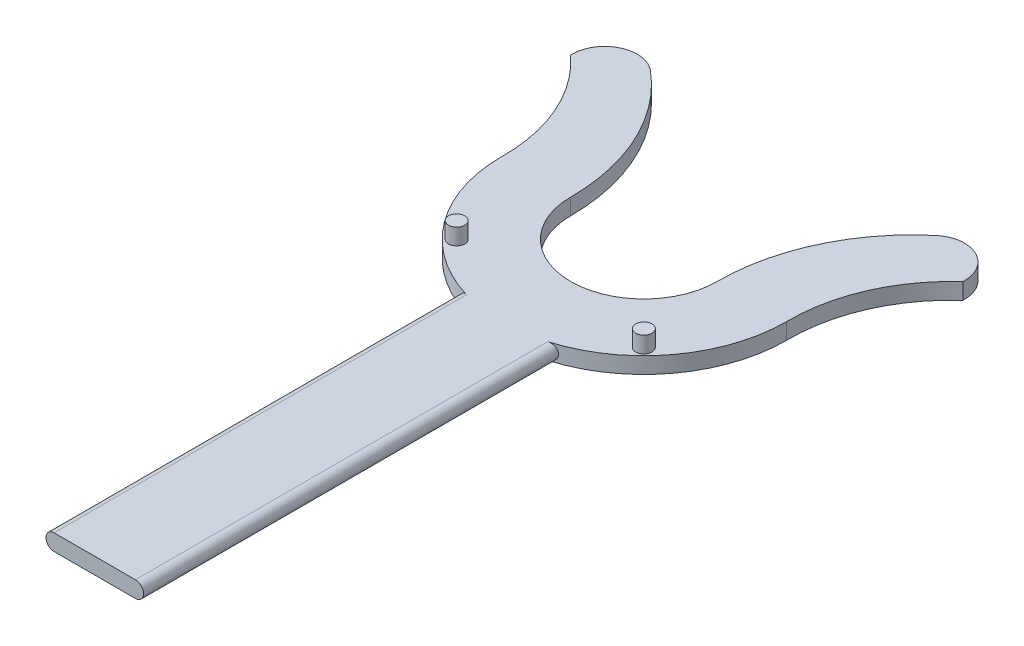
from build123d import *

# Parameters (mm, degrees)
BOSS_EXTRUDE1_DEPTH = 5
SKETCH2_R           = 2.5
BOSS_EXTRUDE2_DEPTH = 5
BOSS_EXTRUDE3_START = -2.644184
BOSS_EXTRUDE3_DEPTH = 127.644184


with BuildPart() as part:
    # Sketch1 → Boss-Extrude1 (new body)
    with BuildSketch(Plane(origin=(0, 0, 0), x_dir=(1, 0, 0), z_dir=(0, 1, 0))):
        with BuildLine():
            ThreePointArc((-22.5, 0), (0, -22.5), (22.5, 0))
            ThreePointArc((22.5, 0), (28.11402228, 25.340983158), (43.905514247, 45.939804848))
            ThreePointArc((43.905514247, 45.939804848), (54.788632448, 47.238126581), (60.325213459, 37.779047778))
            ThreePointArc((60.325213459, 37.779047778), (48.023832429, 20.66372887), (43.868302884, 0))
            ThreePointArc((43.868302884, 0), (0, -43.868302884), (-43.868302884, 0))
            ThreePointArc((-43.868302884, 0), (-48.023832429, 20.66372887), (-60.325213459, 37.779047778))
            ThreePointArc((-60.325213459, 37.779047778), (-54.788632448, 47.238126581), (-43.905514247, 45.939804848))
            ThreePointArc((-43.905514247, 45.939804848), (-28.11402228, 25.340983158), (-22.5, 0))
        make_face()
    extrude(amount=BOSS_EXTRUDE1_DEPTH)

    # Sketch2 → Boss-Extrude2 (add)
    with BuildSketch(Plane(origin=(0, 5, 0), x_dir=(1, 0, 0), z_dir=(0, 1, 0))):
        with Locations((28.779245994, -28.779245994)):
            Circle(SKETCH2_R)
        with Locations((-28.779245994, -28.779245994)):
            Circle(SKETCH2_R)
    extrude(amount=BOSS_EXTRUDE2_DEPTH)

    # Sketch4 → Boss-Extrude3 (add)
    with BuildSketch(Plane(origin=(0, 5, 43.868302884), x_dir=(1, 0, 0), z_dir=(0, 0, 1)).offset(BOSS_EXTRUDE3_START)):
        with BuildLine():
            Line((12.5, -5), (-12.5, -5))
            ThreePointArc((-12.5, -5), (-15, -2.5), (-12.5, 0))
            Line((-12.5, 0), (12.5, 0))
            ThreePointArc((12.5, 0), (15, -2.5), (12.5, -5))
        make_face()
    extrude(amount=BOSS_EXTRUDE3_DEPTH)


solid = part.part
